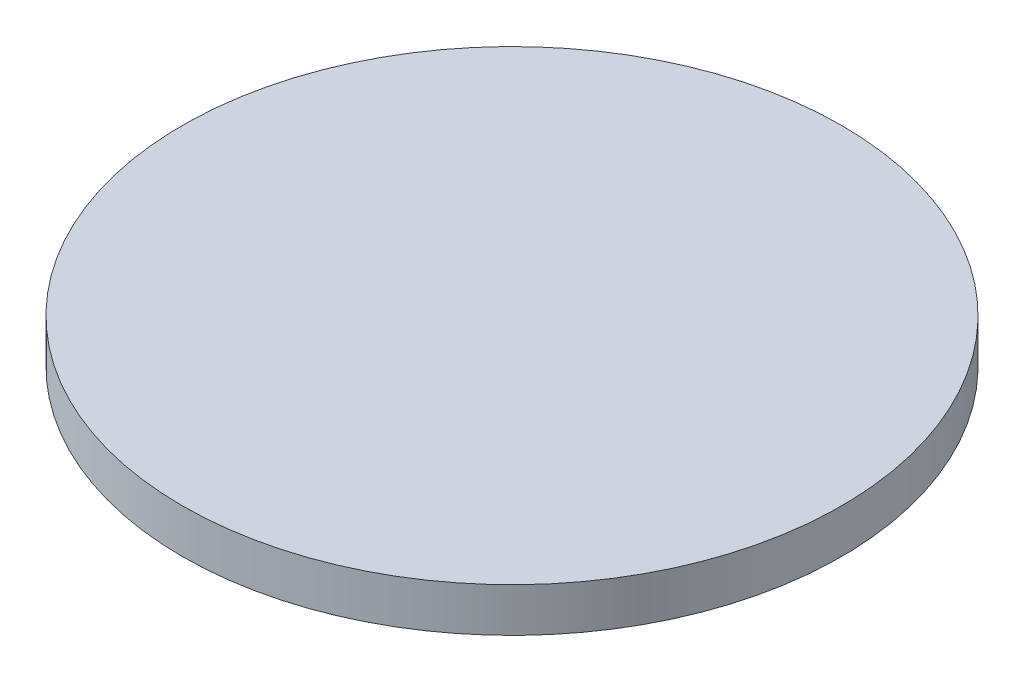
from build123d import *

# Parameters (mm, degrees)
ESQUISSE1_R      = 75
EXTRUSION1_DEPTH = 10


with BuildPart() as part:
    # Esquisse1 → Extrusion1 (new body)
    with BuildSketch(Plane(origin=(0, 0, 0), x_dir=(1, 0, 0), z_dir=(0, 1, 0))):
        Circle(ESQUISSE1_R)
    extrude(amount=EXTRUSION1_DEPTH)


solid = part.part
